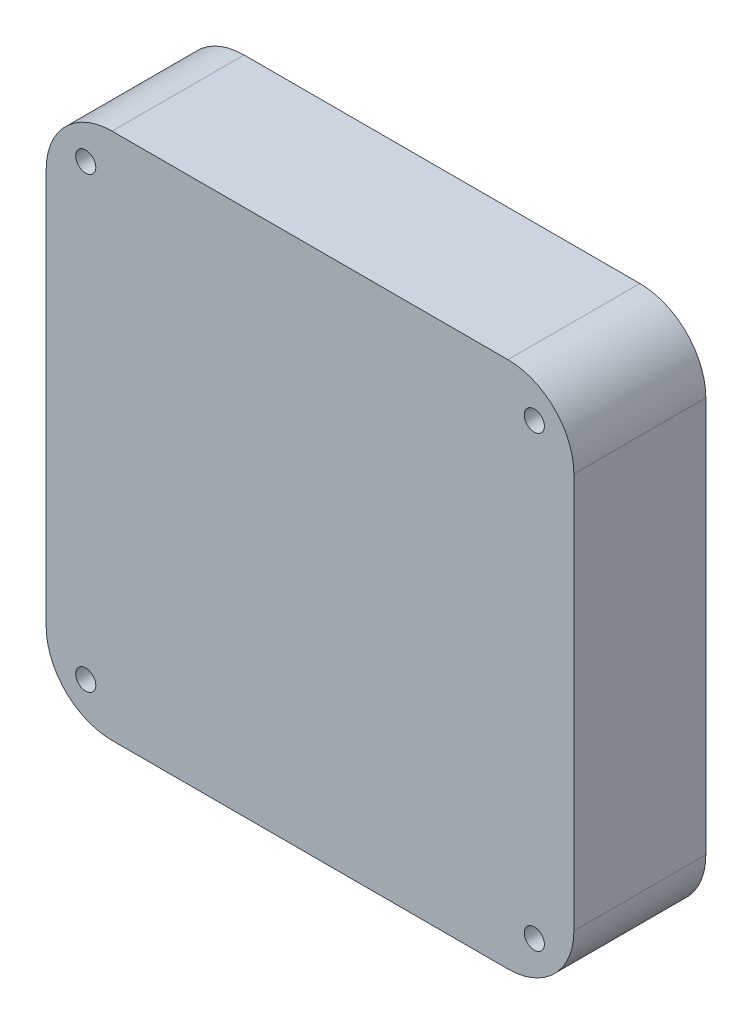
from build123d import *

# Parameters (mm, degrees)
SKETCH1_W             = 40
SKETCH1_H             = 40
BOSS_EXTRUDE1_DEPTH   = 10
F_3_0MM_DOWEL_HOLE1_D = 1.524
MIRROR2_COPY_1_D      = 1.524
FILLET1_R             = 5


with BuildPart() as part:
    # Sketch1 → Boss-Extrude1 (new body)
    with BuildSketch(Plane.XY):
        with Locations((20, 20)):
            Rectangle(SKETCH1_W, SKETCH1_H)
    extrude(amount=BOSS_EXTRUDE1_DEPTH)

    # Ø3.0mm Dowel Hole1 (through all)
    with Locations(Plane.XY.offset(10)):
        with Locations((3, 37)):
            f_3_0mm_dowel_hole1 = Hole(F_3_0MM_DOWEL_HOLE1_D / 2)

    # Mirror1: Ø3.0mm Dowel Hole1 across plane
    add(f_3_0mm_dowel_hole1.mirror(Plane.ZY.offset(-20)), mode=Mode.SUBTRACT)

    # Mirror2: Ø3.0mm Dowel Hole1 across plane
    add(f_3_0mm_dowel_hole1.mirror(Plane.ZX.offset(20)), mode=Mode.SUBTRACT)

    # Mirror2 copy 1 (through all)
    with Locations(Plane(origin=(40, 40, 10), x_dir=(-1, 0, 0), z_dir=(0, 0, 1))):
        with Locations((3, 37)):
            Hole(MIRROR2_COPY_1_D / 2)

    # Fillet1
    fillet1_edges = [part.edges().sort_by_distance(p)[0] for p in [
        (0, 40, 5),
        (40, 40, 5),
        (40, 0, 5),
        (0, 0, 5),
    ]]
    fillet(fillet1_edges, radius=FILLET1_R)


solid = part.part
